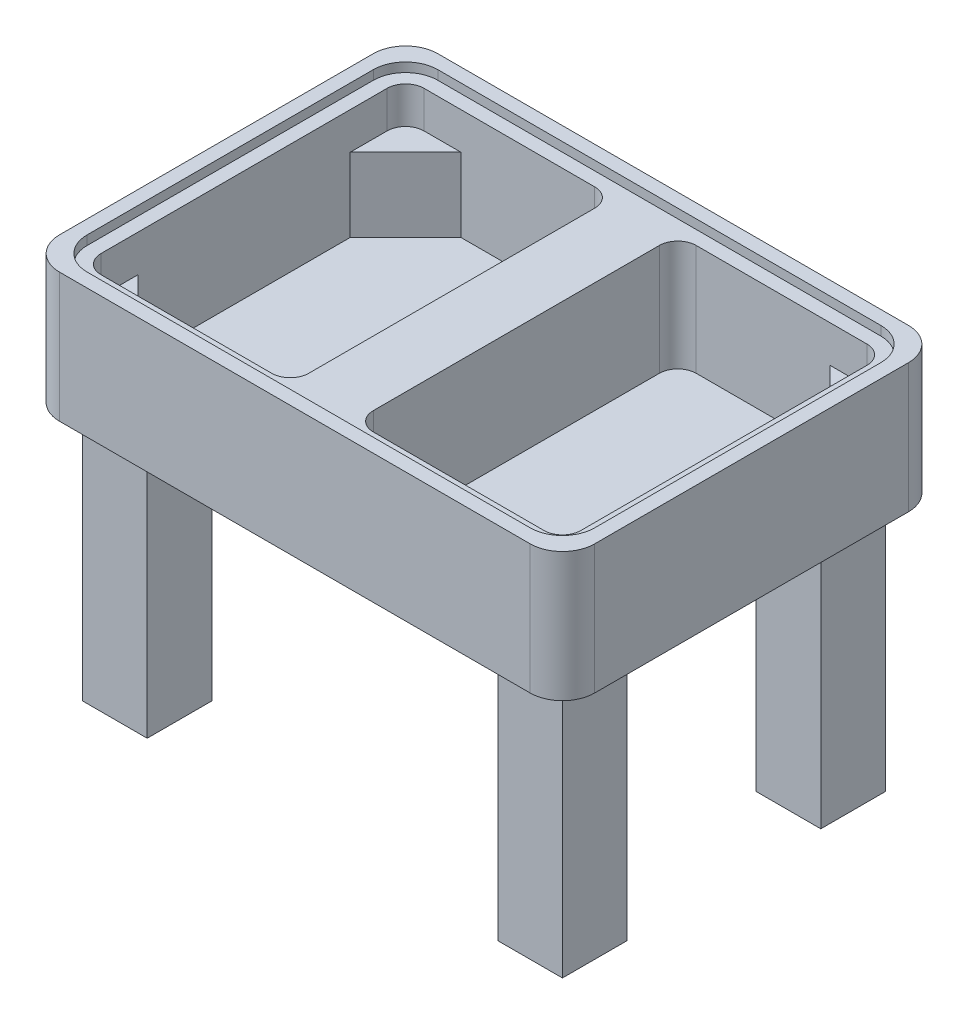
from build123d import *

# Parameters (mm, degrees)
SKETCH1_W           = 580
SKETCH1_H           = 410
BOSS_EXTRUDE1_DEPTH = 140
SKETCH3_W           = 550
SKETCH3_H           = 380
CUT_EXTRUDE1_DEPTH  = 10
SKETCH2_W           = 225
SKETCH2_H           = 350
CUT_EXTRUDE2_DEPTH  = 40
CUT_EXTRUDE3_DEPTH  = 80
FILLET1_R           = 35
SKETCH6_W           = 70
SKETCH6_H           = 70
BOSS_EXTRUDE2_DEPTH = 280
FILLET2_R           = 20


with BuildPart() as part:
    # Sketch1 → Boss-Extrude1 (new body)
    with BuildSketch(Plane(origin=(0, 0, 0), x_dir=(1, 0, 0), z_dir=(0, 1, 0))):
        with Locations((290, 205)):
            Rectangle(SKETCH1_W, SKETCH1_H)
    extrude(amount=-BOSS_EXTRUDE1_DEPTH)

    # Sketch3 → Cut-Extrude1 (cut)
    with BuildSketch(Plane(origin=(0, 0, 0), x_dir=(1, 0, 0), z_dir=(0, 1, 0))):
        with Locations((290, 205)):
            Rectangle(SKETCH3_W, SKETCH3_H)
    extrude(amount=-CUT_EXTRUDE1_DEPTH, mode=Mode.SUBTRACT)

    # Sketch2 → Cut-Extrude2 (cut)
    with BuildSketch(Plane(origin=(0, -10, 0), x_dir=(1, 0, 0), z_dir=(0, 1, 0))):
        with Locations((142.5, 205)):
            Rectangle(SKETCH2_W, SKETCH2_H)
        with Locations((437.5, 205)):
            Rectangle(SKETCH2_W, SKETCH2_H)
    extrude(amount=-CUT_EXTRUDE2_DEPTH, mode=Mode.SUBTRACT)

    # Sketch5 → Cut-Extrude3 (cut)
    with BuildSketch(Plane(origin=(0, -50, 0), x_dir=(1, 0, 0), z_dir=(0, 1, 0))):
        Polygon((30, 320), (90, 380), (255, 380), (255, 30), (90, 30), (30, 90), align=None)
        Polygon((550, 90), (490, 30), (325, 30), (325, 380), (490, 380), (550, 320), align=None)
    extrude(amount=-CUT_EXTRUDE3_DEPTH, mode=Mode.SUBTRACT)

    # Fillet1
    fillet1_edges = [part.edges().sort_by_distance(p)[0] for p in [
        (15, -5, -15),
        (15, -5, -395),
        (565, -5, -395),
        (565, -5, -15),
        (0, -70, -410),
        (580, -70, -410),
        (580, -70, 0),
        (0, -70, 0),
    ]]
    fillet(fillet1_edges, radius=FILLET1_R)

    # Sketch6 → Boss-Extrude2 (add)
    with BuildSketch(Plane.XZ.offset(140)):
        with Locations((65, -65)):
            Rectangle(SKETCH6_W, SKETCH6_H)
        with Locations((515, -65)):
            Rectangle(SKETCH6_W, SKETCH6_H)
        with Locations((515, -345)):
            Rectangle(SKETCH6_W, SKETCH6_H)
        with Locations((65, -345)):
            Rectangle(SKETCH6_W, SKETCH6_H)
    extrude(amount=BOSS_EXTRUDE2_DEPTH)

    # Fillet2
    fillet2_edges = [part.edges().sort_by_distance(p)[0] for p in [
        (30, -30, -30),
        (30, -30, -380),
        (255, -70, -380),
        (255, -70, -30),
        (550, -30, -380),
        (550, -30, -30),
        (325, -70, -30),
        (325, -70, -380),
    ]]
    fillet(fillet2_edges, radius=FILLET2_R)


solid = part.part
